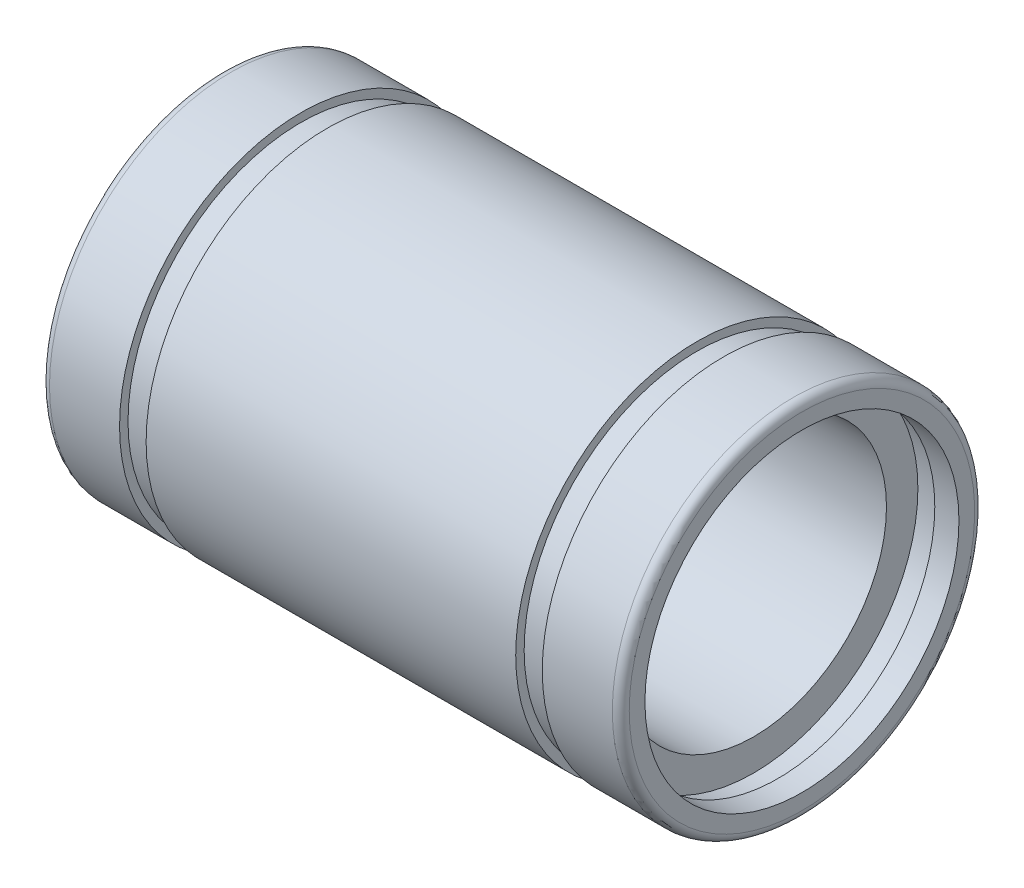
from build123d import *


with BuildPart() as part:
    # Sketch2 → Revolve1 (revolve)
    with BuildSketch(Plane.XY):
        with BuildLine():
            Line((24, 7.15), (24, 6.5))
            Line((24, 6.5), (23, 6.5))
            Line((23, 6.5), (23, 6.8))
            Line((23, 6.8), (22, 6.8))
            Line((22, 6.8), (22, 5.5))
            Line((22, 5.5), (2, 5.5))
            Line((2, 5.5), (2, 6.8))
            Line((2, 6.8), (1, 6.8))
            Line((1, 6.8), (1, 6.5))
            Line((1, 6.5), (0, 6.5))
            Line((0, 6.5), (0, 7.15))
            ThreePointArc((0, 7.15), (0.102512627, 7.397487373), (0.35, 7.5))
            Line((0.35, 7.5), (3.25, 7.5))
            Line((3.25, 7.5), (3.25, 7.15))
            Line((3.25, 7.15), (4.35, 7.15))
            Line((4.35, 7.15), (4.35, 7.5))
            Line((4.35, 7.5), (19.65, 7.5))
            Line((19.65, 7.5), (19.65, 7.15))
            Line((19.65, 7.15), (20.75, 7.15))
            Line((20.75, 7.15), (20.75, 7.5))
            Line((20.75, 7.5), (23.65, 7.5))
            ThreePointArc((23.65, 7.5), (23.897487373, 7.397487373), (24, 7.15))
        make_face()
    revolve(axis=Axis((0, 0, 0), (1, 0, 0)))


solid = part.part
